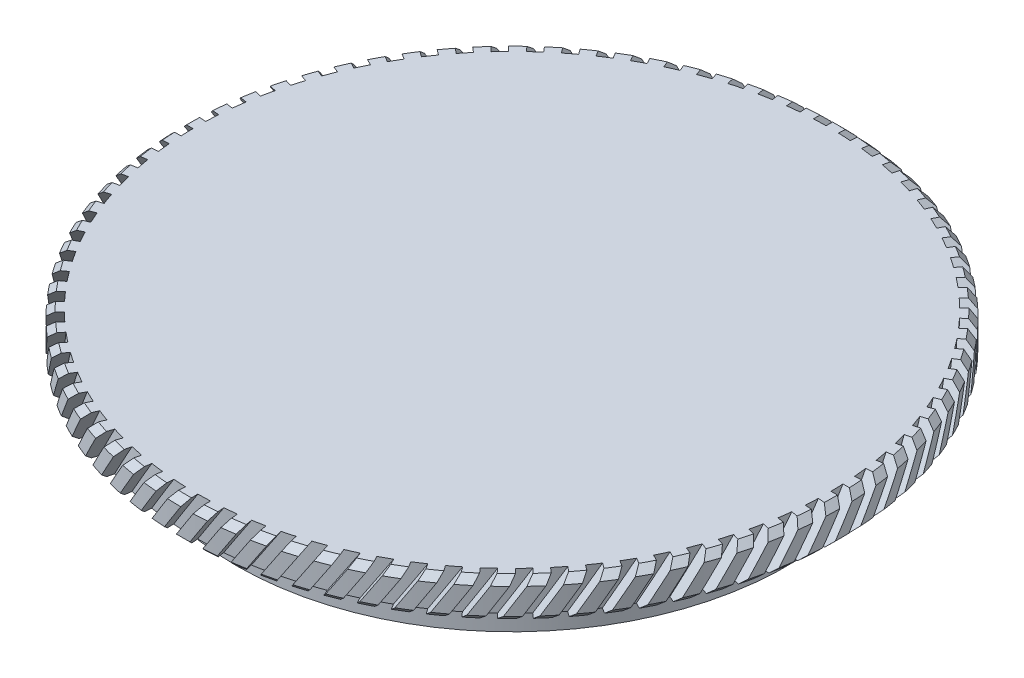
from build123d import *

# Parameters (mm, degrees)
CHAMFER_1_SIZE           = 0.5
CUT_EXTRUDE_1_REACH      = 74.056
CUT_EXTRUDE_1_END_RADIUS = 24.4
CUT_EXTRUDE_START        = 30
PATTERN_CIRCULAR_2_COUNT = 80


with BuildPart() as part:
    # 草图1 → 旋转2 (revolve)
    with BuildSketch(Plane.XY, mode=Mode.PRIVATE) as revolve_2_sk:
        Polygon((0, 21.871257405), (25.4, 21.871257405), (25.4, 18.871257405), (20.5, 18.871257405), (20.5, 17.871257405), (21.2, 17.871257405), (21.2, 15.371257405), (16, 15.371257405), (16, 18.871257405), (0, 18.871257405), align=None)
    revolve(revolve_2_sk.sketch.rotate(Axis((0, 66.628762136, 0), (0, -1, 0)), 90), axis=Axis((0, 66.628762136, 0), (0, -1, 0)))

    # 倒角1
    chamfer_1_edges = [part.edges().sort_by_distance(p)[0] for p in [
        (0, 21.871257405, -25.4),
        (0, 18.871257405, -25.4),
    ]]
    chamfer(chamfer_1_edges, length=CHAMFER_1_SIZE)

    # 切除-拉伸1: up to this cylinder (the profile starts outside it)
    cut_extrude_1_end = Plane(origin=(0, 18.072086, 0), z_dir=(0, 1, 0)) * Cylinder(CUT_EXTRUDE_1_END_RADIUS, 197.912, mode=Mode.PRIVATE)
    # 草图2 → 切除-拉伸1 (cut, up to the surface)
    with BuildSketch(Plane.XY.offset(CUT_EXTRUDE_START), mode=Mode.PRIVATE) as cut_extrude_1_sk1:
        Polygon((1.108168834, 23.303253722), (-5.339513804, 13.273525174), (-4.666571024, 12.840919101), (1.781111614, 22.870647649), align=None)
    cut_extrude_1_tool1 = extrude(cut_extrude_1_sk1.sketch, amount=-CUT_EXTRUDE_1_REACH, mode=Mode.PRIVATE) - cut_extrude_1_end
    cut_extrude_1 = cut_extrude_1_tool1.solids().sort_by_distance((-1.779201, 18.072086, 30))[0]
    add(cut_extrude_1, mode=Mode.SUBTRACT)

    # 阵列(圆周)2: 切除-拉伸1 ×80 about axis
    pattern_circular_2_axis = Axis((0, 0, 0), (0, 1, 0))
    for i in range(1, PATTERN_CIRCULAR_2_COUNT):
        add(cut_extrude_1.rotate(pattern_circular_2_axis, i * 360 / PATTERN_CIRCULAR_2_COUNT), mode=Mode.SUBTRACT)


solid = part.part
